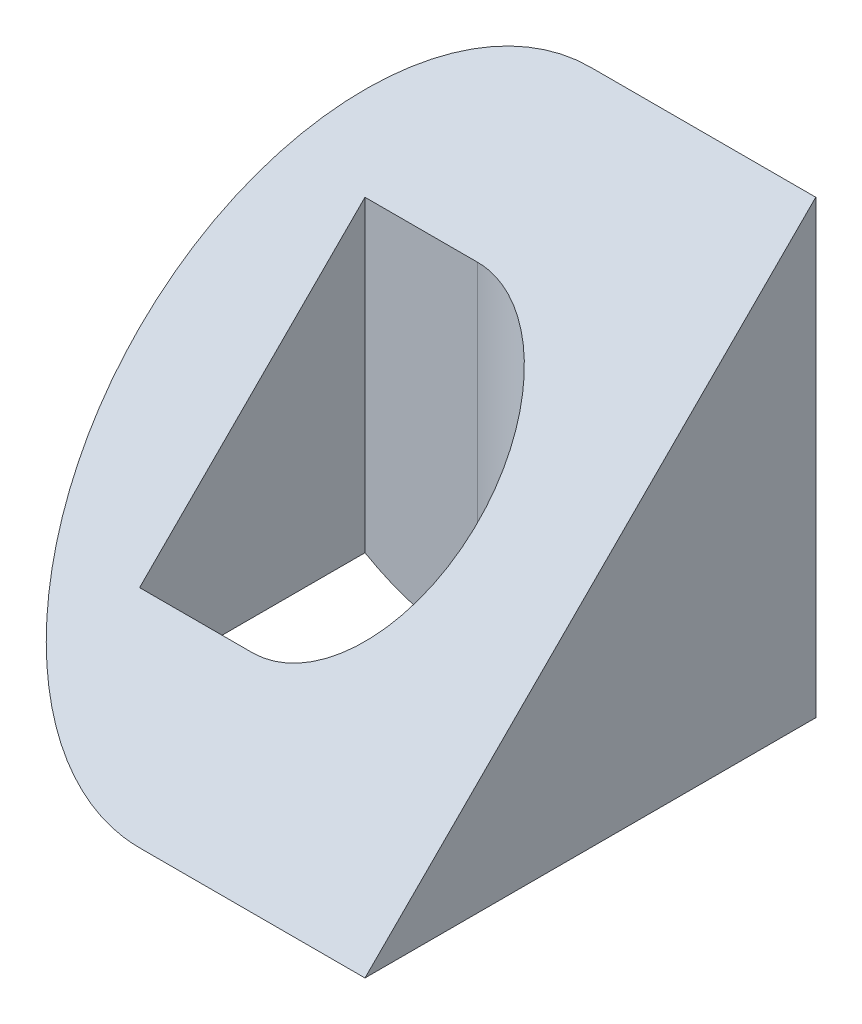
from build123d import *

# Parameters (mm, degrees)
SKETCH1_W           = 60
SKETCH1_H           = 60
BOSS_EXTRUDE1_DEPTH = 60
CUT_EXTRUDE1_DEPTH  = 60
CUT_EXTRUDE2_DEPTH  = 60
CUT_EXTRUDE3_DEPTH  = 60
CUT_EXTRUDE6_DEPTH  = 60


with BuildPart() as part:
    # Sketch1 → Boss-Extrude1 (new body)
    with BuildSketch(Plane.XY):
        with Locations((30, 30)):
            Rectangle(SKETCH1_W, SKETCH1_H)
    extrude(amount=BOSS_EXTRUDE1_DEPTH)

    # Sketch2 → Cut-Extrude1 (cut)
    with BuildSketch(Plane.XY.offset(60)):
        with BuildLine():
            ThreePointArc((0, 30), (8.786796564, 51.213203436), (30, 60))
            Line((30, 60), (0, 60))
            Line((0, 60), (0, 30))
        make_face()
        with BuildLine():
            ThreePointArc((30, 0), (8.786796564, 8.786796564), (0, 30))
            Line((0, 30), (0, 0))
            Line((0, 0), (30, 0))
        make_face()
    extrude(amount=-CUT_EXTRUDE1_DEPTH, mode=Mode.SUBTRACT)

    # Sketch3 → Cut-Extrude2 (cut)
    with BuildSketch(Plane(origin=(0, 60, 0), x_dir=(1, 0, 0), z_dir=(0, 1, 0))):
        with BuildLine():
            ThreePointArc((0, -29.999999939), (8.786796586, -8.786796543), (30, 0))
            Line((30, 0), (0, 0))
            Line((0, 0), (0, -29.999999939))
        make_face()
        with BuildLine():
            Line((0, -60), (30, -60))
            ThreePointArc((30, -60), (8.786796543, -51.213203414), (0, -29.999999939))
            Line((0, -29.999999939), (0, -60))
        make_face()
    extrude(amount=-CUT_EXTRUDE2_DEPTH, mode=Mode.SUBTRACT)

    # Sketch4 → Cut-Extrude3 (cut)
    with BuildSketch(Plane(origin=(0, 0, 0), x_dir=(0, 0, -1), z_dir=(1, 0, 0))):
        Polygon((0, 60), (-60, 60), (-60, 0), align=None)
    extrude(amount=CUT_EXTRUDE3_DEPTH, mode=Mode.SUBTRACT)

    # Sketch6 → Cut-Extrude6 (cut)
    with BuildSketch(Plane(origin=(0, 60, 0), x_dir=(1, 0, 0), z_dir=(0, 1, 0))):
        with BuildLine():
            Line((15, -15), (15, -45))
            Line((15, -45), (30, -45))
            ThreePointArc((30, -45), (45, -30), (30, -15))
            Line((30, -15), (15, -15))
        make_face()
    extrude(amount=-CUT_EXTRUDE6_DEPTH, mode=Mode.SUBTRACT)


solid = part.part
